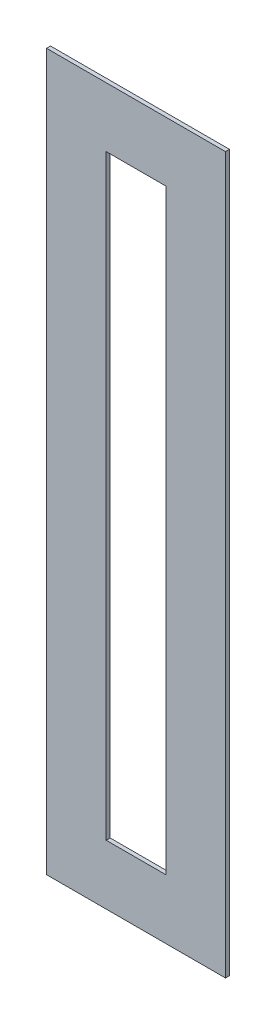
from build123d import *

# Parameters (mm, degrees)
SKETCH1_W           = 9
SKETCH1_H           = 36
SKETCH1_W_2         = 3
SKETCH1_H_2         = 30
BOSS_EXTRUDE1_DEPTH = 0.2


with BuildPart() as part:
    # Sketch1 → Boss-Extrude1 (new body)
    with BuildSketch(Plane.XY):
        Rectangle(SKETCH1_W, SKETCH1_H)
        Rectangle(SKETCH1_W_2, SKETCH1_H_2, mode=Mode.SUBTRACT)
    extrude(amount=BOSS_EXTRUDE1_DEPTH)


solid = part.part
